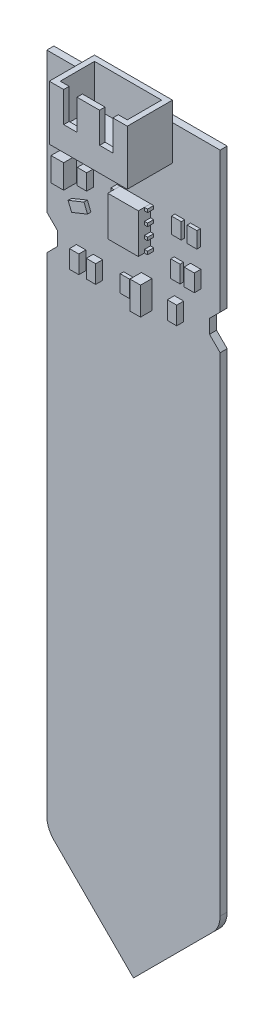
from build123d import *

# Parameters (mm, degrees)
BOSS_EXTRUDE1_DEPTH       = 0.9
SKETCH2_W                 = 3.91
SKETCH2_H                 = 5.08
BOSS_EXTRUDE2_DEPTH       = 1.57
SKETCH2_3_W               = 1.25
SKETCH2_3_H               = 2.05
BOSS_EXTRUDE3_DEPTH       = 0.44
BOSS_EXTRUDE3_2_DEPTH     = 0.44
SKETCH2_3_W_2             = 1.2
SKETCH2_3_H_2             = 2.2
BOSS_EXTRUDE3_3_DEPTH     = 0.44
BOSS_EXTRUDE3_4_DEPTH     = 0.44
SKETCH2_3_H_3             = 2.16
BOSS_EXTRUDE3_5_DEPTH     = 0.44
SKETCH2_4_W               = 1.61
SKETCH2_4_H               = 3.05
BOSS_EXTRUDE4_DEPTH       = 1.65
SKETCH2_5_W               = 1.2
SKETCH2_5_H               = 2.3
BOSS_EXTRUDE5_DEPTH       = 0.9
BOSS_EXTRUDE5_2_DEPTH     = 0.9
SKETCH2_5_H_2             = 2.04
BOSS_EXTRUDE5_3_DEPTH     = 0.9
BOSS_EXTRUDE5_4_DEPTH     = 0.9
SKETCH2_6_W               = 1.35
SKETCH2_6_H               = 3.56
BOSS_EXTRUDE6_DEPTH       = 1.46
SKETCH2_7_W               = 1.32
SKETCH2_7_H               = 2.2
BOSS_EXTRUDE7_DEPTH       = 0.83
SKETCH4_W                 = 10
SKETCH4_H                 = 7
BOSS_EXTRUDE8_DEPTH       = 5.8
SHELL1_T                  = -0.7
SHELL1_THICKNESS_2_FACE_W = 4.4
SHELL1_THICKNESS_2_FACE_H = 8.6
SHELL1_THICKNESS_2_DEPTH  = 1.14
SKETCH5_W                 = 1.7
SKETCH5_H                 = 3.9
CUT_EXTRUDE1_DEPTH        = 0.7
SKETCH6_W                 = 0.7
SKETCH6_H                 = 0.7
BOSS_EXTRUDE9_DEPTH       = 2.5
BOSS_EXTRUDE9_2_DEPTH     = 2.5
BOSS_EXTRUDE9_3_DEPTH     = 2.5
SKETCH7_W                 = 0.4
SKETCH7_H                 = 0.4
BOSS_EXTRUDE10_DEPTH      = 0.785
BOSS_EXTRUDE10_2_DEPTH    = 0.785
BOSS_EXTRUDE10_3_DEPTH    = 0.785
BOSS_EXTRUDE10_4_DEPTH    = 0.785


with BuildPart() as part:
    # Sketch1 → Boss-Extrude1 (new body)
    with BuildSketch(Plane.XY):
        with BuildLine():
            Line((-11.1125, 0), (11.1125, 0))
            Line((11.1125, 0), (11.1125, -18))
            Line((11.1125, -18), (9.75, -19.3625))
            Line((9.75, -19.3625), (9.75, -21.1375))
            Line((9.75, -21.1375), (11.1125, -22.5))
            Line((11.1125, -22.5), (11.1125, -85.072371939))
            ThreePointArc((11.1125, -85.072371939), (10.870817516, -86.287391837), (10.18256403, -87.31743597))
            Line((10.18256403, -87.31743597), (0, -97.5))
            Line((0, -97.5), (-10.18256403, -87.31743597))
            ThreePointArc((-10.18256403, -87.31743597), (-10.870817516, -86.287391837), (-11.1125, -85.072371939))
            Line((-11.1125, -85.072371939), (-11.1125, -22.5))
            Line((-11.1125, -22.5), (-9.75, -21.1375))
            Line((-9.75, -21.1375), (-9.75, -19.3625))
            Line((-9.75, -19.3625), (-11.1125, -18))
            Line((-11.1125, -18), (-11.1125, 0))
        make_face()
    extrude(amount=BOSS_EXTRUDE1_DEPTH)


with BuildPart() as body_2:
    # Sketch2 → Boss-Extrude2 (new body)
    with BuildSketch(Plane.XY.offset(0.9)):
        with Locations((0.2325, -12.96)):
            Rectangle(SKETCH2_W, SKETCH2_H)
    extrude(amount=BOSS_EXTRUDE2_DEPTH)


with BuildPart() as body_3:
    # Sketch2_3 → Boss-Extrude3 (new body)
    with BuildSketch(Plane.XY.offset(0.9)):
        with Locations((7.9375, -11.025)):
            Rectangle(SKETCH2_3_W, SKETCH2_3_H)
    extrude(amount=BOSS_EXTRUDE3_DEPTH)


with BuildPart() as body_4:
    # Sketch2_3 → Boss-Extrude3 2 (new body)
    with BuildSketch(Plane.XY.offset(0.9)):
        with Locations((5.9375, -11.025)):
            Rectangle(SKETCH2_3_W, SKETCH2_3_H)
    extrude(amount=BOSS_EXTRUDE3_2_DEPTH)


with BuildPart() as body_5:
    # Sketch2_3 → Boss-Extrude3 3 (new body)
    with BuildSketch(Plane.XY.offset(0.9)):
        with Locations((5.8125, -15.9)):
            Rectangle(SKETCH2_3_W_2, SKETCH2_3_H_2)
    extrude(amount=BOSS_EXTRUDE3_3_DEPTH)


with BuildPart() as body_6:
    # Sketch2_3 → Boss-Extrude3 4 (new body)
    with BuildSketch(Plane.XY.offset(0.9)):
        Polygon((-7.9475, -14.888300075), (-5.909383471, -14.06), (-5.45758343, -15.171699925), (-7.495699959, -16), align=None)
    extrude(amount=BOSS_EXTRUDE3_4_DEPTH)


with BuildPart() as body_7:
    # Sketch2_3 → Boss-Extrude3 5 (new body)
    with BuildSketch(Plane.XY.offset(0.9)):
        with Locations((-0.6675, -20.78)):
            Rectangle(SKETCH2_3_W_2, SKETCH2_3_H_3)
    extrude(amount=BOSS_EXTRUDE3_5_DEPTH)


with BuildPart() as body_8:
    # Sketch2_4 → Boss-Extrude4 (new body)
    with BuildSketch(Plane.XY.offset(0.9)):
        with Locations((-8.1175, -11.315)):
            Rectangle(SKETCH2_4_W, SKETCH2_4_H)
    extrude(amount=BOSS_EXTRUDE4_DEPTH)


with BuildPart() as body_9:
    # Sketch2_5 → Boss-Extrude5 (new body)
    with BuildSketch(Plane.XY.offset(0.9)):
        with Locations((-6.7125, -20.85)):
            Rectangle(SKETCH2_5_W, SKETCH2_5_H)
    extrude(amount=BOSS_EXTRUDE5_DEPTH)


with BuildPart() as body_10:
    # Sketch2_5 → Boss-Extrude5 2 (new body)
    with BuildSketch(Plane.XY.offset(0.9)):
        with Locations((-4.5525, -20.85)):
            Rectangle(SKETCH2_5_W, SKETCH2_5_H)
    extrude(amount=BOSS_EXTRUDE5_2_DEPTH)


with BuildPart() as body_11:
    # Sketch2_5 → Boss-Extrude5 3 (new body)
    with BuildSketch(Plane.XY.offset(0.9)):
        with Locations((-5.7125, -11.2)):
            Rectangle(SKETCH2_5_W, SKETCH2_5_H_2)
    extrude(amount=BOSS_EXTRUDE5_3_DEPTH)


with BuildPart() as body_12:
    # Sketch2_5 → Boss-Extrude5 4 (new body)
    with BuildSketch(Plane.XY.offset(0.9)):
        with Locations((5.8425, -20.25)):
            Rectangle(SKETCH2_5_W, SKETCH2_5_H)
    extrude(amount=BOSS_EXTRUDE5_4_DEPTH)


with BuildPart() as body_13:
    # Sketch2_6 → Boss-Extrude6 (new body)
    with BuildSketch(Plane.XY.offset(0.9)):
        with Locations((1.6875, -20.42)):
            Rectangle(SKETCH2_6_W, SKETCH2_6_H)
    extrude(amount=BOSS_EXTRUDE6_DEPTH)


with BuildPart() as body_14:
    # Sketch2_7 → Boss-Extrude7 (new body)
    with BuildSketch(Plane.XY.offset(0.9)):
        with Locations((7.9725, -15.57)):
            Rectangle(SKETCH2_7_W, SKETCH2_7_H)
    extrude(amount=BOSS_EXTRUDE7_DEPTH)


with BuildPart() as body_15:
    # Sketch4 → Boss-Extrude8 (new body)
    with BuildSketch(Plane.XY.offset(0.9)):
        with Locations((0, -1)):
            Rectangle(SKETCH4_W, SKETCH4_H)
    extrude(amount=BOSS_EXTRUDE8_DEPTH)

    # Shell1
    shell1_openings = [body_15.faces().sort_by_distance(p)[0] for p in [
        (0, 2.5, 3.8),
    ]]
    offset(amount=SHELL1_T, openings=shell1_openings, kind=Kind.INTERSECTION)

    # Shell1 thickness 2 face (on inner face of the shell) → Shell1 thickness 2 (add)
    with BuildSketch(Plane(origin=(0, -3.8, 3.8), x_dir=(0, 0, -1), z_dir=(0, -1, 0))):
        Rectangle(SHELL1_THICKNESS_2_FACE_W, SHELL1_THICKNESS_2_FACE_H)
    extrude(amount=-SHELL1_THICKNESS_2_DEPTH)

    # Sketch5 → Cut-Extrude1 (cut)
    with BuildSketch(Plane.XY.offset(6.7)):
        with Locations((-2.3, 0.55)):
            Rectangle(SKETCH5_W, SKETCH5_H)
        with Locations((2.3, 0.55)):
            Rectangle(SKETCH5_W, SKETCH5_H)
    extrude(amount=-CUT_EXTRUDE1_DEPTH, mode=Mode.SUBTRACT)


with BuildPart() as body_16:
    # Sketch6 → Boss-Extrude9 (new body)
    with BuildSketch(Plane(origin=(0, 0, 0), x_dir=(-1, 0, 0), z_dir=(0, 0, -1))):
        with Locations((-2.54, -4.5)):
            Rectangle(SKETCH6_W, SKETCH6_H)
    extrude(amount=BOSS_EXTRUDE9_DEPTH)


with BuildPart() as body_17:
    # Sketch6 → Boss-Extrude9 2 (new body)
    with BuildSketch(Plane(origin=(0, 0, 0), x_dir=(-1, 0, 0), z_dir=(0, 0, -1))):
        with Locations((0, -4.5)):
            Rectangle(SKETCH6_W, SKETCH6_H)
    extrude(amount=BOSS_EXTRUDE9_2_DEPTH)


with BuildPart() as body_18:
    # Sketch6 → Boss-Extrude9 3 (new body)
    with BuildSketch(Plane(origin=(0, 0, 0), x_dir=(-1, 0, 0), z_dir=(0, 0, -1))):
        with Locations((2.54, -4.5)):
            Rectangle(SKETCH6_W, SKETCH6_H)
    extrude(amount=BOSS_EXTRUDE9_3_DEPTH)


with BuildPart() as body_19:
    # Sketch7 → Boss-Extrude10 (new body)
    with BuildSketch(Plane(origin=(0, 0, 1.685), x_dir=(-1, 0, 0), z_dir=(0, 0, -1))):
        with Locations((-2.3875, -15.3)):
            Rectangle(SKETCH7_W, SKETCH7_H)
    extrude(amount=BOSS_EXTRUDE10_DEPTH)


with BuildPart() as body_20:
    # Sketch7 → Boss-Extrude10 2 (new body)
    with BuildSketch(Plane(origin=(0, 0, 1.685), x_dir=(-1, 0, 0), z_dir=(0, 0, -1))):
        with Locations((-2.3875, -13.74)):
            Rectangle(SKETCH7_W, SKETCH7_H)
    extrude(amount=BOSS_EXTRUDE10_2_DEPTH)


with BuildPart() as body_21:
    # Sketch7 → Boss-Extrude10 3 (new body)
    with BuildSketch(Plane(origin=(0, 0, 1.685), x_dir=(-1, 0, 0), z_dir=(0, 0, -1))):
        with Locations((-2.3875, -12.18)):
            Rectangle(SKETCH7_W, SKETCH7_H)
    extrude(amount=BOSS_EXTRUDE10_3_DEPTH)


with BuildPart() as body_22:
    # Sketch7 → Boss-Extrude10 4 (new body)
    with BuildSketch(Plane(origin=(0, 0, 1.685), x_dir=(-1, 0, 0), z_dir=(0, 0, -1))):
        with Locations((-2.3875, -10.62)):
            Rectangle(SKETCH7_W, SKETCH7_H)
    extrude(amount=BOSS_EXTRUDE10_4_DEPTH)


with BuildPart() as body_23:
    # Mirror1: mirrored copy
    add(body_19.part.mirror(Plane(origin=(0.2325, 0, 0), x_dir=(0, 0, 1), z_dir=(1, 0, 0))))


with BuildPart() as body_24:
    # Mirror1 2: mirrored copy
    add(body_20.part.mirror(Plane(origin=(0.2325, 0, 0), x_dir=(0, 0, 1), z_dir=(1, 0, 0))))


with BuildPart() as body_25:
    # Mirror1 3: mirrored copy
    add(body_21.part.mirror(Plane(origin=(0.2325, 0, 0), x_dir=(0, 0, 1), z_dir=(1, 0, 0))))


with BuildPart() as body_26:
    # Mirror1 4: mirrored copy
    add(body_22.part.mirror(Plane(origin=(0.2325, 0, 0), x_dir=(0, 0, 1), z_dir=(1, 0, 0))))


solid = Compound([part.part, body_2.part, body_3.part, body_4.part, body_5.part, body_6.part, body_7.part, body_8.part, body_9.part, body_10.part, body_11.part, body_12.part, body_13.part, body_14.part, body_15.part, body_16.part, body_17.part, body_18.part, body_19.part, body_20.part, body_21.part, body_22.part, body_23.part, body_24.part, body_25.part, body_26.part])
